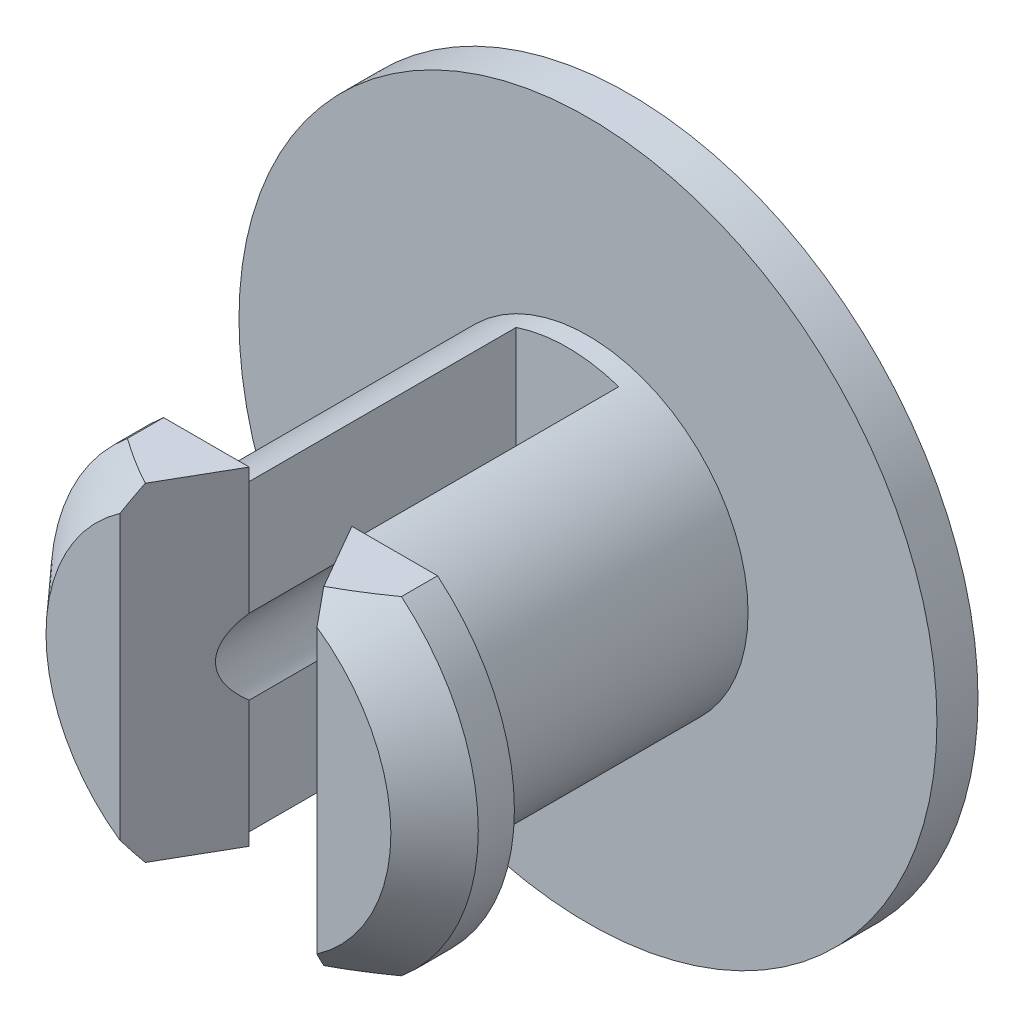
from build123d import *

# Parameters (mm, degrees)
SKETCH1_R                = 8.5
BOSS_EXTRUDE1_DEPTH      = 6
BOSS_EXTRUDE1_DEPTH_BACK = 4.5
SKETCH2_R                = 8.5
SKETCH2_R_2              = 3.9
CUT_EXTRUDE1_DEPTH       = 3.5
CUT_EXTRUDE1_DEPTH_BACK  = 3.5
SKETCH3_R                = 8.5
SKETCH3_R_2              = 6
CUT_EXTRUDE2_DEPTH       = 3.5
CUT_EXTRUDE4_DEPTH       = 3.5
CUT_EXTRUDE5_DEPTH       = 8.5
SKETCH10_R               = 1.55
CUT_EXTRUDE6_DEPTH       = 10
CUT_EXTRUDE7_DEPTH       = 8


with BuildPart() as part:
    # Sketch1 → Boss-Extrude1 (new body, two sides)
    with BuildSketch(Plane.XY) as boss_extrude1_sk:
        Circle(SKETCH1_R)
    extrude(amount=BOSS_EXTRUDE1_DEPTH)
    extrude(boss_extrude1_sk.sketch, amount=-BOSS_EXTRUDE1_DEPTH_BACK)

    # Sketch2 → Cut-Extrude1 (cut, two sides)
    with BuildSketch(Plane.XY) as cut_extrude1_sk:
        Circle(SKETCH2_R)
        Circle(SKETCH2_R_2, mode=Mode.SUBTRACT)
    extrude(amount=CUT_EXTRUDE1_DEPTH, mode=Mode.SUBTRACT)
    extrude(cut_extrude1_sk.sketch, amount=-CUT_EXTRUDE1_DEPTH_BACK, mode=Mode.SUBTRACT)

    # Sketch3 → Cut-Extrude2 (cut)
    with BuildSketch(Plane(origin=(0, 0, 3.5), x_dir=(-1, 0, 0), z_dir=(0, 0, -1))):
        Circle(SKETCH3_R)
        Circle(SKETCH3_R_2, mode=Mode.SUBTRACT)
    extrude(amount=-CUT_EXTRUDE2_DEPTH, mode=Mode.SUBTRACT)

    # Sketch6 → Cut-Revolve1 (revolve, cut)
    with BuildSketch(Plane(origin=(0, 0, 0), x_dir=(0, 0, -1), z_dir=(1, 0, 0))):
        Polygon((-5.5, 0), (-5.5, 4.2), (-4.379199334, 5.208720599), (-3.5, 5.208720599), (-3.5, 6), (-6, 6), (-6, 0), align=None)
    revolve(axis=Axis((0, 0, -5.814918194), (0, 0, 1)), mode=Mode.SUBTRACT)

    # Sketch8 → Cut-Extrude4 (cut)
    with BuildSketch(Plane(origin=(0, 0, 3.5), x_dir=(-1, 0, 0), z_dir=(0, 0, -1))):
        Polygon((-10, 4), (0, 4), (10, 4), (10, 8.647445608), (-10, 8.647445608), align=None)
        Polygon((10, -4), (0, -4), (-10, -4), (-10, -8.418803799), (10, -8.418803799), align=None)
    extrude(amount=-CUT_EXTRUDE4_DEPTH, mode=Mode.SUBTRACT)

    # Sketch9 → Cut-Extrude5 (cut)
    with BuildSketch(Plane.XY.offset(5.5)):
        Polygon((0, 4), (-1.25, 4), (-1.25, -4), (1.25, -4), (1.25, 4), align=None)
    extrude(amount=-CUT_EXTRUDE5_DEPTH, mode=Mode.SUBTRACT)

    # Sketch10 → Cut-Extrude6 (cut)
    with BuildSketch(Plane(origin=(0, 0, -4.5), x_dir=(-1, 0, 0), z_dir=(0, 0, -1))):
        Circle(SKETCH10_R)
    extrude(amount=-CUT_EXTRUDE6_DEPTH, mode=Mode.SUBTRACT)

    # Sketch12 → Cut-Extrude7 (cut)
    with BuildSketch(Plane(origin=(0, 4, 0), x_dir=(1, 0, 0), z_dir=(0, 1, 0))):
        Polygon((-1.25, -3.5), (-1.25, -5.5), (-2.4, -5.5), align=None)
        Polygon((1.25, -5.5), (2.4, -5.5), (1.25, -3.5), align=None)
    extrude(amount=-CUT_EXTRUDE7_DEPTH, mode=Mode.SUBTRACT)


solid = part.part
